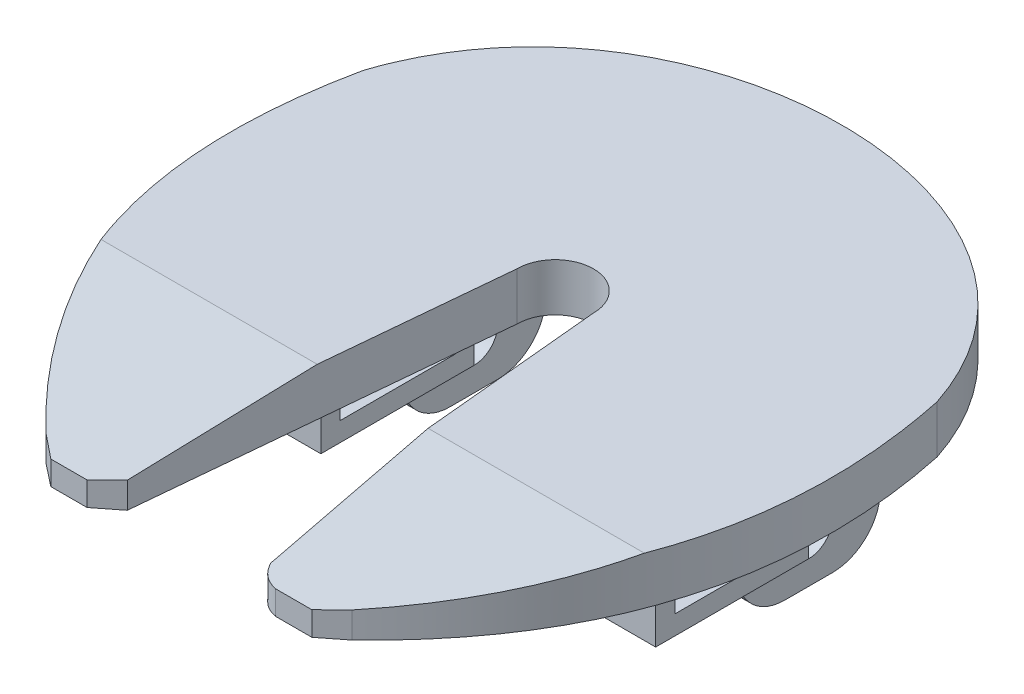
from build123d import *

# Parameters (mm, degrees)
BOSS_EXTRUDE1_DEPTH = 5
SKETCH2_W           = 20
SKETCH2_H           = 2
BOSS_EXTRUDE2_DEPTH = 3
SKETCH3_W           = 20
SKETCH3_H           = 16
BOSS_EXTRUDE3_DEPTH = 2
CUT_EXTRUDE1_DEPTH  = 62.362825506
SKETCH6_W           = 5
SKETCH6_H           = 15
BOSS_EXTRUDE4_DEPTH = 15
SKETCH7_R           = 2.5
CUT_EXTRUDE2_DEPTH  = 40
FILLET1_R           = 5
SKETCH8_W           = 2
SKETCH8_H           = 12
BOSS_EXTRUDE5_DEPTH = 3


with BuildPart() as part:
    # Sketch1 → Boss-Extrude1 (new body)
    with BuildSketch(Plane(origin=(0, 0, 0), x_dir=(1, 0, 0), z_dir=(0, 1, 0))):
        with BuildLine():
            Line((26, -9.914732545), (22.5, -47.146428929))
            Line((22.5, -47.146428929), (20.1411286, -49))
            Line((20.1411286, -49), (16.3588714, -49))
            Line((16.3588714, -49), (14, -47.146428929))
            add(Edge.make_bspline(
                [(0, 0), (-5.93850555, -28.119223668), (14, -47.146428929)],
                knots=[0, 0, 0, 1, 1, 1], degree=2))
            add(Edge.make_bspline(
                [(0, 0), (8.75, 26.780356607), (51.25, 26.780356607), (60, 0)],
                knots=[0, 0, 0, 0, 1, 1, 1, 1], degree=3))
            add(Edge.make_bspline(
                [(60, 0), (65.93850555, -28.119223668), (46, -47.146428929)],
                knots=[0, 0, 0, 1, 1, 1], degree=2))
            Line((46, -47.146428929), (43.6411286, -49))
            Line((43.6411286, -49), (39.8588714, -49))
            add(Edge.make_bspline(
                [(37.5, -47.146428929), (38.196873938, -48.687326951), (39.8588714, -49)],
                knots=[0, 0, 0, 1, 1, 1], degree=2))
            Line((37.5, -47.146428929), (34, -9.914732545))
            ThreePointArc((34, -9.914732545), (30, -5.914732545), (26, -9.914732545))
        make_face()
    extrude(amount=BOSS_EXTRUDE1_DEPTH)

    # Sketch2 → Boss-Extrude2 (add)
    with BuildSketch(Plane.XZ):
        with Locations((47.5, 11.914732545)):
            Rectangle(SKETCH2_W, SKETCH2_H)
        with Locations((47.5, 25.914732545)):
            Rectangle(SKETCH2_W, SKETCH2_H)
        with Locations((12.5, 11.914732545)):
            Rectangle(SKETCH2_W, SKETCH2_H)
        with Locations((12.5, 25.914732545)):
            Rectangle(SKETCH2_W, SKETCH2_H)
    extrude(amount=BOSS_EXTRUDE2_DEPTH)

    # Sketch3 → Boss-Extrude3 (add)
    with BuildSketch(Plane.XZ.offset(3)):
        with Locations((47.5, 18.914732545)):
            Rectangle(SKETCH3_W, SKETCH3_H)
        with Locations((12.5, 18.914732545)):
            Rectangle(SKETCH3_W, SKETCH3_H)
    extrude(amount=BOSS_EXTRUDE3_DEPTH)

    # Sketch5 → Cut-Extrude1 (cut, through all)
    with BuildSketch(Plane(origin=(0, 0, 0), x_dir=(0, 0, -1), z_dir=(1, 0, 0))):
        Polygon((-29, 5), (-49, 2.5), (-49, 5), align=None)
    extrude(amount=CUT_EXTRUDE1_DEPTH, mode=Mode.SUBTRACT)

    # Sketch6 → Boss-Extrude4 (add)
    with BuildSketch(Plane.XZ):
        with Locations((12.5, 3.414732545)):
            Rectangle(SKETCH6_W, SKETCH6_H)
    boss_extrude4 = extrude(amount=BOSS_EXTRUDE4_DEPTH)

    # Mirror1: Boss-Extrude4 across plane
    add(boss_extrude4.mirror(Plane(origin=(30, 0, 0), x_dir=(0, 0, 1), z_dir=(1, 0, 0))))

    # Sketch7 → Cut-Extrude2 (cut)
    with BuildSketch(Plane.ZY.offset(-10)):
        with Locations((3.414732545, -10)):
            Circle(SKETCH7_R)
    extrude(amount=-CUT_EXTRUDE2_DEPTH, mode=Mode.SUBTRACT)

    # Fillet1
    fillet1_edges = [part.edges().sort_by_distance(p)[0] for p in [
        (12.5, -15, 10.914732545),
        (12.5, -15, -4.085267455),
        (47.5, -15, 10.914732545),
        (47.5, -15, -4.085267455),
    ]]
    fillet(fillet1_edges, radius=FILLET1_R)

    # Sketch8 → Boss-Extrude5 (add)
    with BuildSketch(Plane.XZ):
        with Locations((3.5, 18.914732545)):
            Rectangle(SKETCH8_W, SKETCH8_H)
    extrude(amount=BOSS_EXTRUDE5_DEPTH)


solid = part.part
